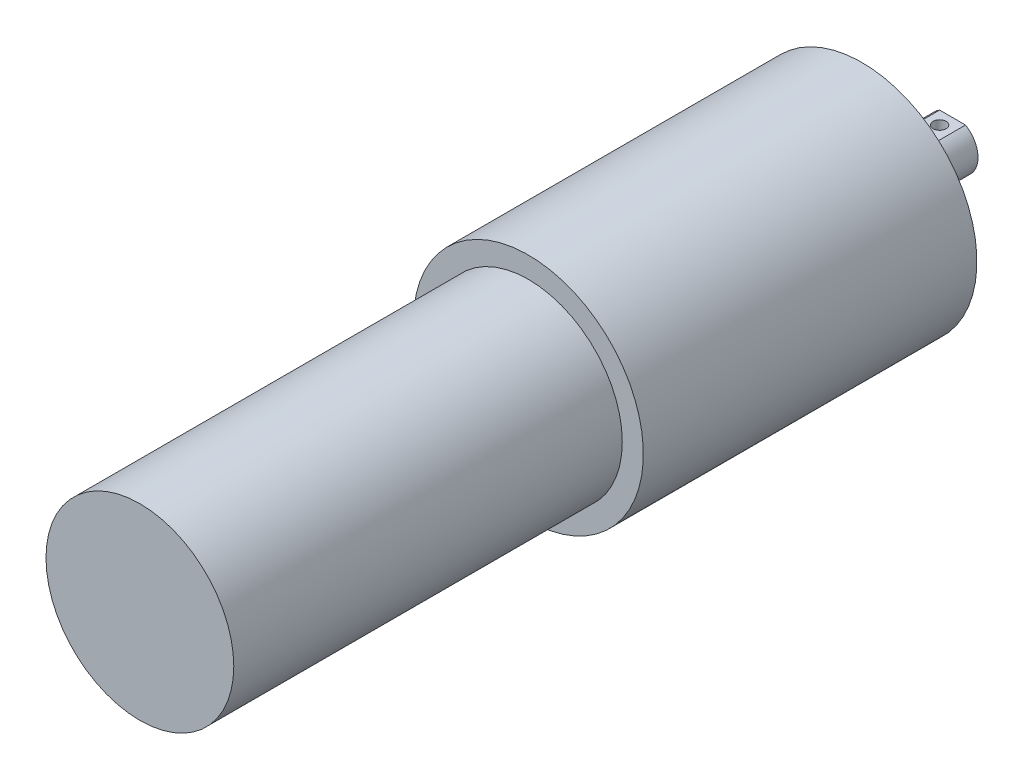
from build123d import *

# Parameters (mm, degrees)
SKETCH1_R           = 18.415
BOSS_EXTRUDE1_DEPTH = 76.2
SKETCH2_R           = 22.54885
BOSS_EXTRUDE2_DEPTH = 65.4177
SKETCH3_R           = 4.9911
BOSS_EXTRUDE3_DEPTH = 17.78
SKETCH5_W           = 5.08
SKETCH5_H           = 1.253731976
CUT_EXTRUDE1_DEPTH  = 7.62
CUT_EXTRUDE2_REACH  = 28.845
SKETCH6_R           = 1.27


with BuildPart() as part:
    # Sketch1 → Boss-Extrude1 (new body)
    with BuildSketch(Plane.XY):
        Circle(SKETCH1_R)
    extrude(amount=BOSS_EXTRUDE1_DEPTH)

    # Sketch2 → Boss-Extrude2 (add)
    with BuildSketch(Plane(origin=(0, 0, 0), x_dir=(-1, 0, 0), z_dir=(0, 0, -1))):
        Circle(SKETCH2_R)
    extrude(amount=BOSS_EXTRUDE2_DEPTH)

    # Sketch3 → Boss-Extrude3 (add)
    with BuildSketch(Plane(origin=(0, 0, -65.4177), x_dir=(-1, 0, 0), z_dir=(0, 0, -1))):
        Circle(SKETCH3_R)
    extrude(amount=BOSS_EXTRUDE3_DEPTH)

    # Sketch5 → Cut-Extrude1 (cut)
    with BuildSketch(Plane(origin=(0, 0, -83.1977), x_dir=(-1, 0, 0), z_dir=(0, 0, -1))):
        with Locations((0, 4.923315593)):
            Rectangle(SKETCH5_W, SKETCH5_H)
    extrude(amount=-CUT_EXTRUDE1_DEPTH, mode=Mode.SUBTRACT)

    # Sketch6 → Cut-Extrude2 (cut, up to next)
    with BuildSketch(Plane(origin=(0, 4.296449605, 0), x_dir=(1, 0, 0), z_dir=(0, 1, 0)), mode=Mode.PRIVATE) as cut_extrude2_sk1:
        with Locations((0, 80.6577)):
            Circle(SKETCH6_R)
    cut_extrude2_tool1 = extrude(cut_extrude2_sk1.sketch, amount=-CUT_EXTRUDE2_REACH, mode=Mode.PRIVATE) & part.part
    add(cut_extrude2_tool1.solids().sort_by_distance((0, 4.29645, -80.6577))[0], mode=Mode.SUBTRACT)


solid = part.part
